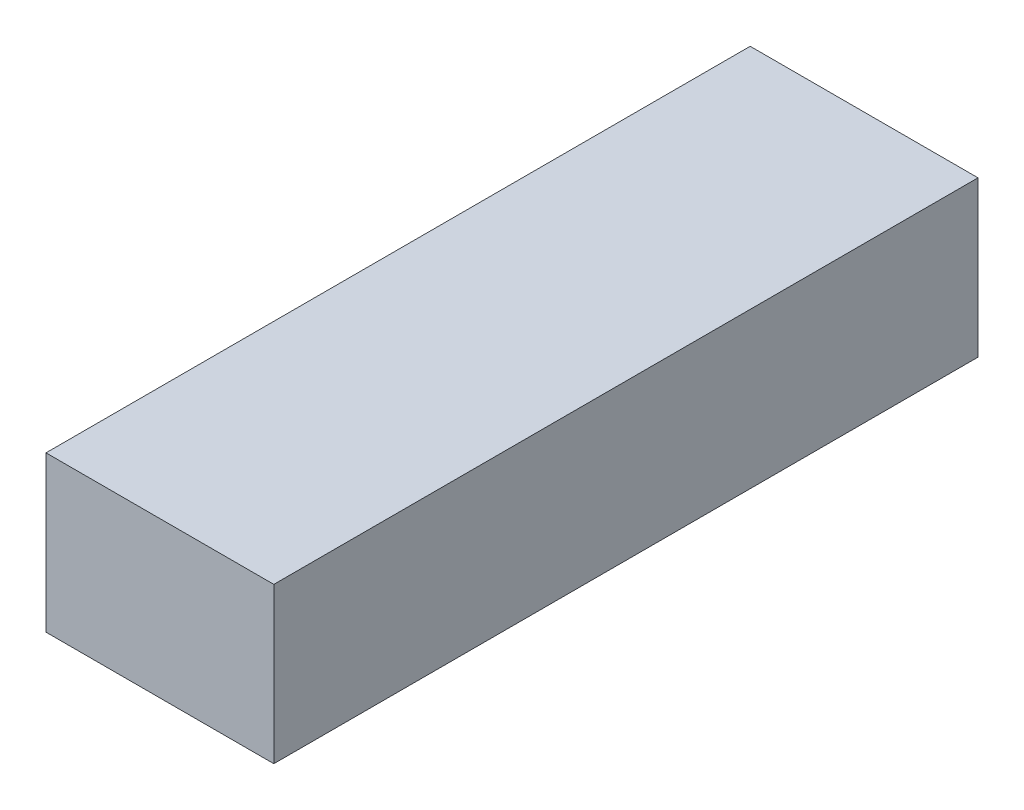
from build123d import *

# Parameters (mm, degrees)
SKETCH1_W           = 44
SKETCH1_H           = 136
BOSS_EXTRUDE1_DEPTH = 30


with BuildPart() as part:
    # Sketch1 → Boss-Extrude1 (new body)
    with BuildSketch(Plane(origin=(0, 0, 0), x_dir=(1, 0, 0), z_dir=(0, 1, 0))):
        with Locations((0.838095238, -19.6)):
            Rectangle(SKETCH1_W, SKETCH1_H)
    extrude(amount=BOSS_EXTRUDE1_DEPTH)


solid = part.part
